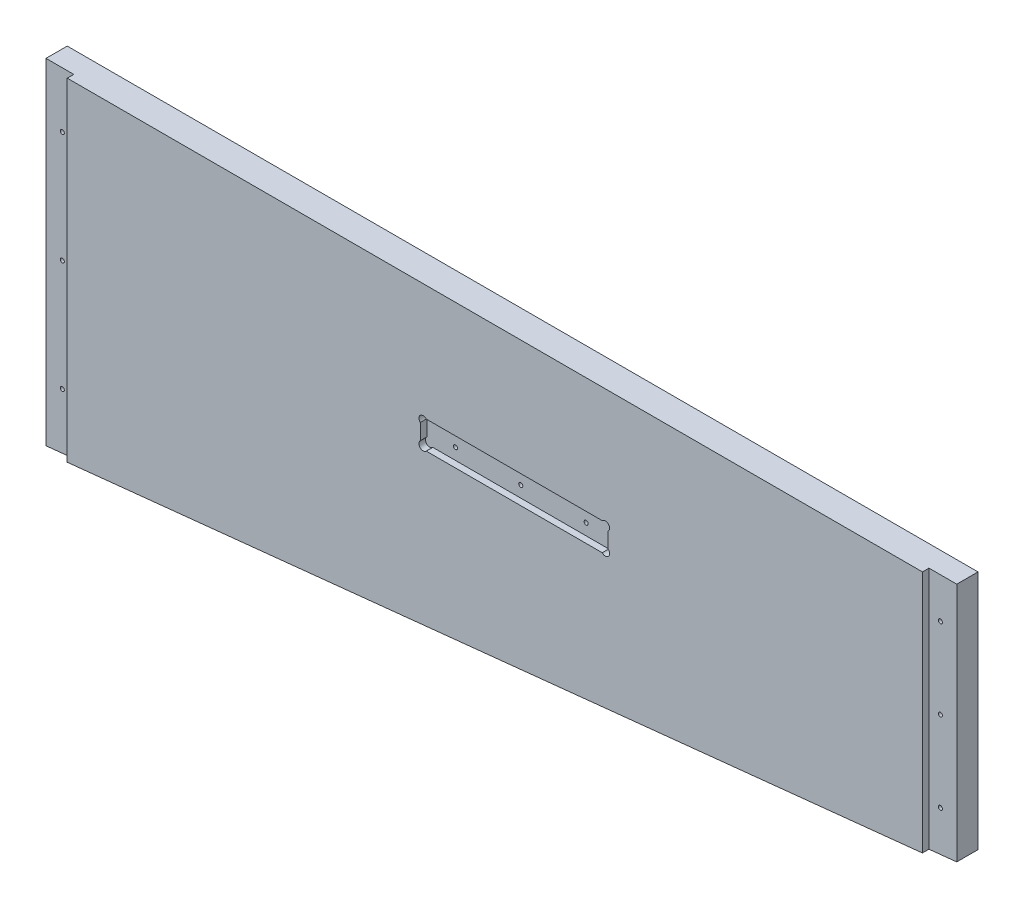
from build123d import *

# Parameters (mm, degrees)
EXTRUDE1_DEPTH     = 21.59
EXTRUDE2_DEPTH     = 16.51
SKETCH4_W          = 146.050000002
SKETCH4_H          = 21.59
CUT_EXTRUDE2_DEPTH = 5.08
SKETCH6_R          = 3.302000001
SKETCH6_R_2        = 3.302
CUT_EXTRUDE3_DEPTH = 5.08
SKETCH3_R          = 1.5875
CUT_EXTRUDE1_DEPTH = 21.59


with BuildPart() as part:
    # Sketch2 → Extrude1 (new body)
    with BuildSketch(Plane.XY):
        Polygon((839.47, -5504.129603175), (839.47, -5314.95), (174.9425, -5314.95), (174.9425, -5573.445396825), align=None)
    extrude(amount=-EXTRUDE1_DEPTH)

    # Sketch7 → Extrude2 (add)
    with BuildSketch(Plane(origin=(0, 0, -21.59), x_dir=(-1, 0, 0), z_dir=(0, 0, -1))):
        Polygon((-174.9425, -5314.95), (-153.3525, -5314.95), (-153.3525, -5575.697414966), (-174.9425, -5573.445396825), align=None)
        Polygon((-839.47, -5314.95), (-861.06, -5314.95), (-861.06, -5501.877585034), (-839.47, -5504.129603175), align=None)
    extrude(amount=-EXTRUDE2_DEPTH)

    # Sketch4 → Cut-Extrude2 (cut)
    with BuildSketch(Plane.XY):
        with Locations((522.2875, -5415.661000001)):
            Rectangle(SKETCH4_W, SKETCH4_H)
    extrude(amount=-CUT_EXTRUDE2_DEPTH, mode=Mode.SUBTRACT)

    # Sketch6 → Cut-Extrude3 (cut)
    with BuildSketch(Plane.XY):
        with Locations((451.507564029, -5407.111064031)):
            Circle(SKETCH6_R)
        with Locations((451.507564029, -5424.210935971)):
            Circle(SKETCH6_R_2)
        with Locations((593.067435971, -5424.210935971)):
            Circle(SKETCH6_R_2)
        with Locations((593.067435971, -5407.111064031)):
            Circle(SKETCH6_R)
    extrude(amount=-CUT_EXTRUDE3_DEPTH, mode=Mode.SUBTRACT)

    # Sketch3 → Cut-Extrude1 (cut)
    with BuildSketch(Plane.XY):
        with Locations((166.0525, -5531.135582009)):
            Circle(SKETCH3_R)
        with Locations((166.0525, -5444.661349205)):
            Circle(SKETCH3_R)
        with Locations((166.0525, -5358.187116401)):
            Circle(SKETCH3_R)
        with Locations((848.36, -5471.826917991)):
            Circle(SKETCH3_R)
        with Locations((848.36, -5409.076150795)):
            Circle(SKETCH3_R)
        with Locations((848.36, -5346.325383599)):
            Circle(SKETCH3_R)
        with Locations((573.0875, -5417.566)):
            Circle(SKETCH3_R)
        with Locations((522.2875, -5417.566)):
            Circle(SKETCH3_R)
        with Locations((471.4875, -5417.566)):
            Circle(SKETCH3_R)
    extrude(amount=-CUT_EXTRUDE1_DEPTH, mode=Mode.SUBTRACT)


solid = part.part
